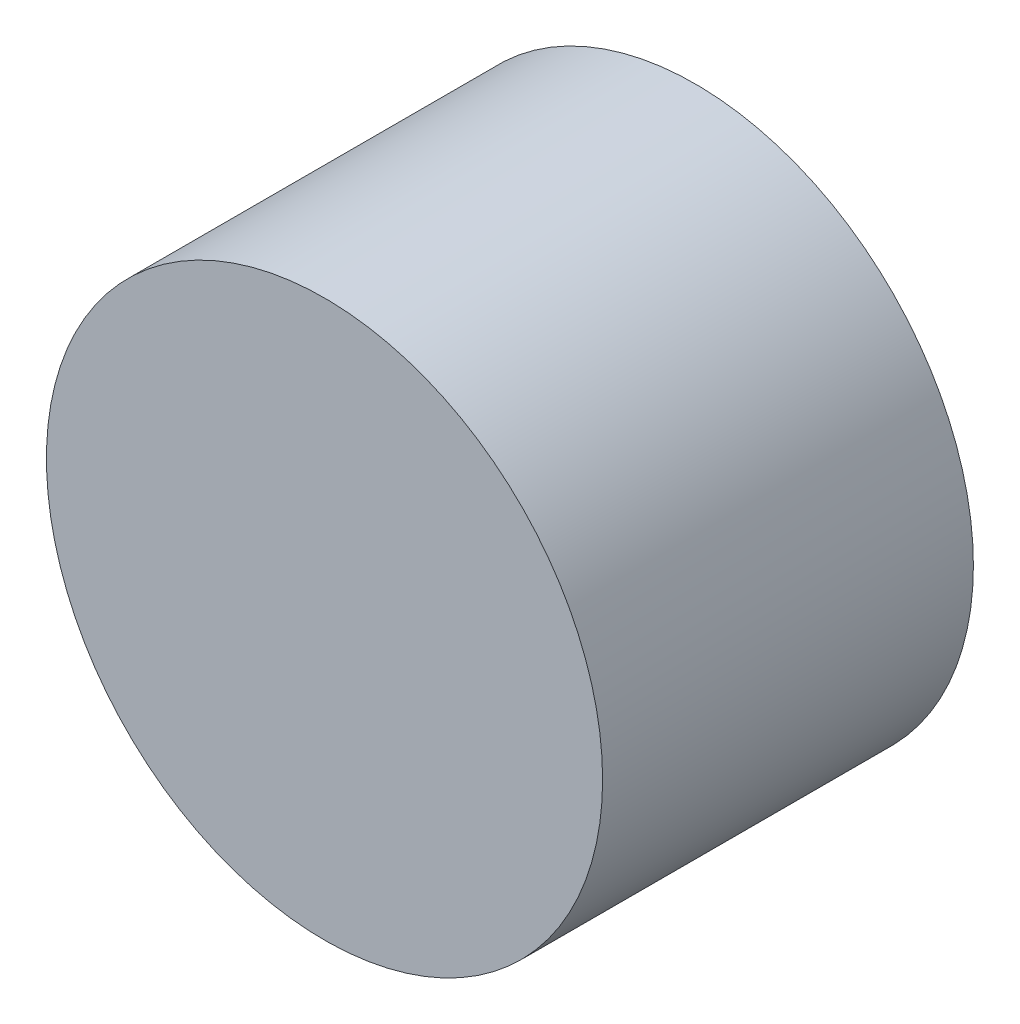
from build123d import *

# Parameters (mm, degrees)
SKETCH_1_R      = 1.5
EXTRUDE_1_DEPTH = 2


with BuildPart() as part:
    # 草图1 → 凸台-拉伸1 (new body)
    with BuildSketch(Plane.XY):
        Circle(SKETCH_1_R)
    extrude(amount=EXTRUDE_1_DEPTH)


solid = part.part
